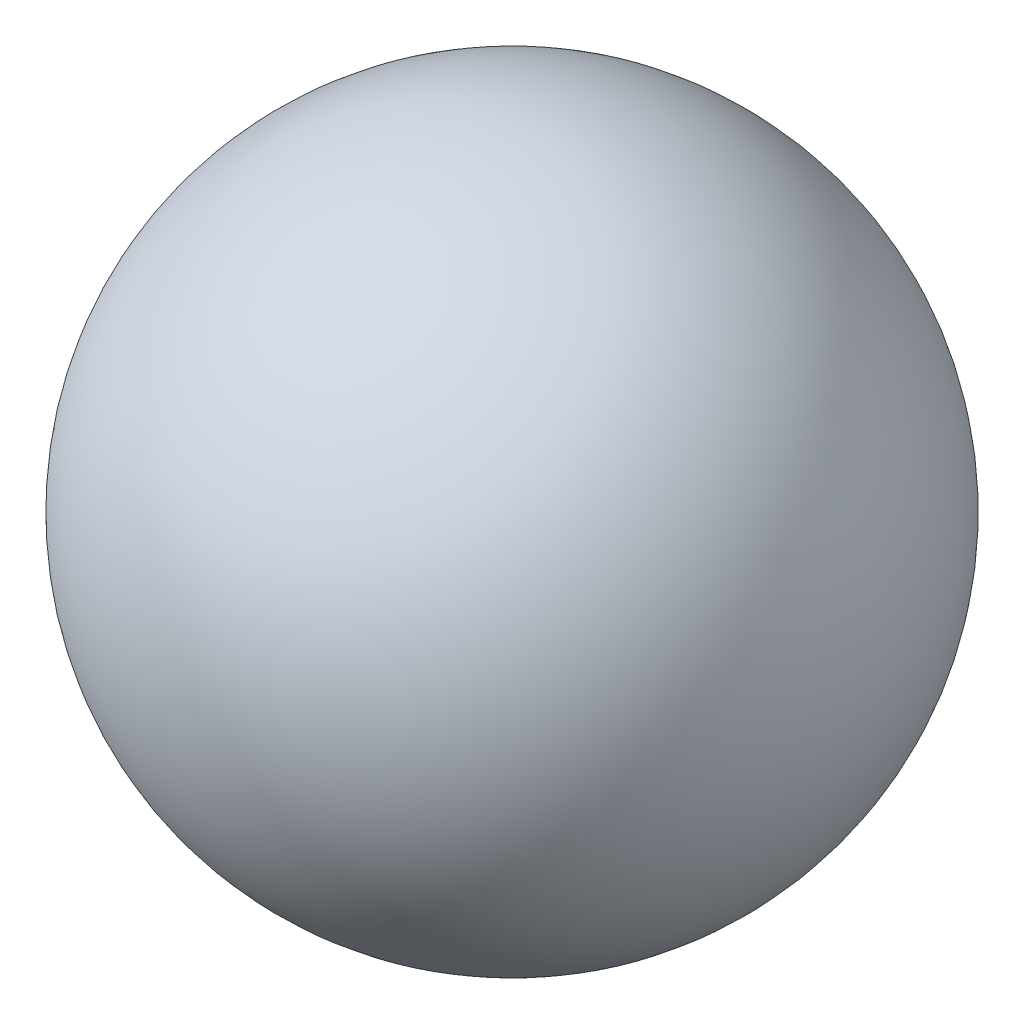
from build123d import *


with BuildPart() as part:
    # Sketch1 → Revolve4 (revolve)
    with BuildSketch(Plane.XY):
        with BuildLine():
            Line((0, 12.7), (0, -12.7))
            ThreePointArc((0, -12.7), (12.7, 0), (0, 12.7))
        make_face()
    revolve(axis=Axis((0, 12.7, 0), (0, -1, 0)))


solid = part.part
